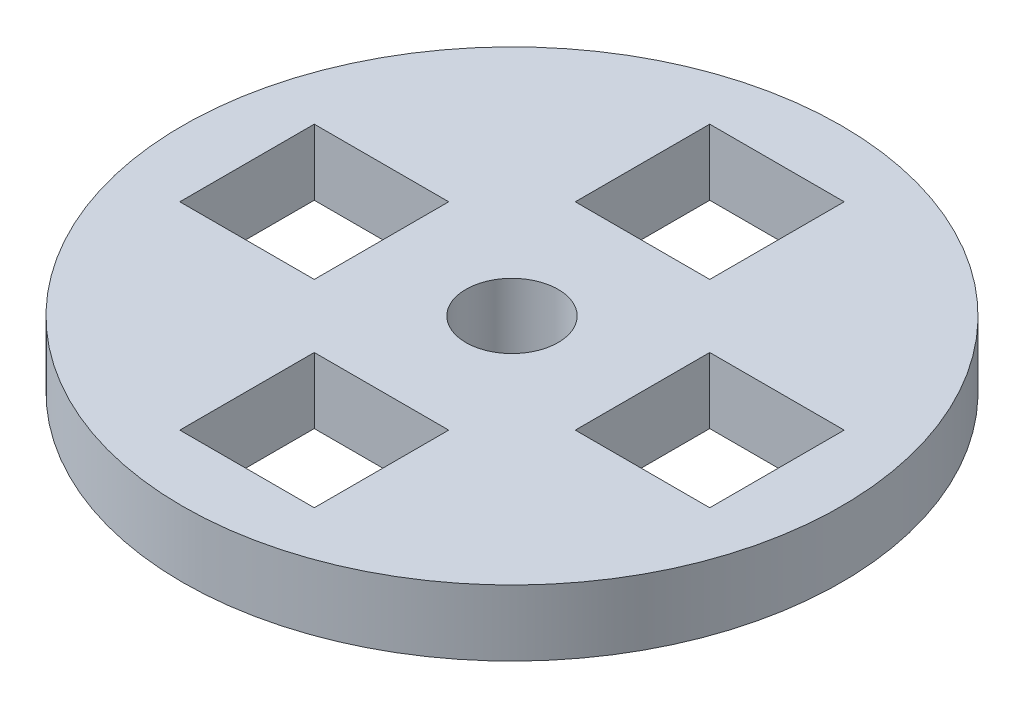
from build123d import *

# Parameters (mm, degrees)
CROQUIS1_R              = 25
CROQUIS1_W              = 10.2
CROQUIS1_H              = 10.2
SALIENTE_EXTRUIR1_DEPTH = 5
CROQUIS2_R              = 3.5
CORTAR_EXTRUIR1_DEPTH   = 47


with BuildPart() as part:
    # Croquis1 → Saliente-Extruir1 (new body)
    with BuildSketch(Plane(origin=(0, 0, 0), x_dir=(1, 0, 0), z_dir=(0, 1, 0))):
        Circle(CROQUIS1_R)
        with Locations((-15, 0)):
            Rectangle(CROQUIS1_W, CROQUIS1_H, mode=Mode.SUBTRACT)
        with Locations((15, 0)):
            Rectangle(CROQUIS1_W, CROQUIS1_H, mode=Mode.SUBTRACT)
        with Locations((0, 15)):
            Rectangle(CROQUIS1_W, CROQUIS1_H, mode=Mode.SUBTRACT)
        with Locations((0, -15)):
            Rectangle(CROQUIS1_W, CROQUIS1_H, mode=Mode.SUBTRACT)
    extrude(amount=SALIENTE_EXTRUIR1_DEPTH)

    # Croquis2 → Cortar-Extruir1 (cut)
    with BuildSketch(Plane(origin=(0, 5, 0), x_dir=(1, 0, 0), z_dir=(0, 1, 0))):
        Circle(CROQUIS2_R)
    extrude(amount=-CORTAR_EXTRUIR1_DEPTH, mode=Mode.SUBTRACT)


solid = part.part
